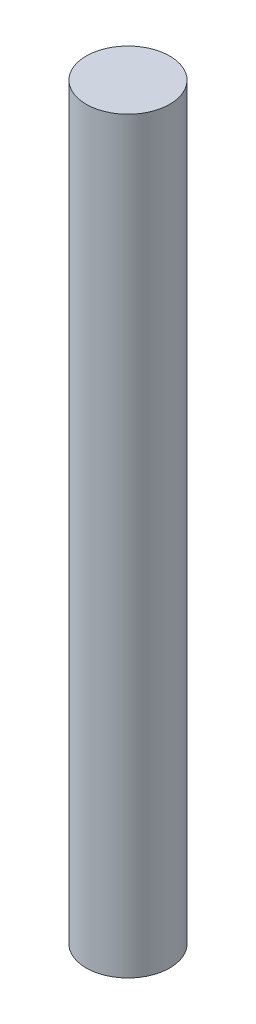
from build123d import *

# Parameters (mm, degrees)
SKETCH1_R           = 1.9
BOSS_EXTRUDE1_DEPTH = 34


with BuildPart() as part:
    # Sketch1 → Boss-Extrude1 (new body)
    with BuildSketch(Plane(origin=(0, 0, 0), x_dir=(1, 0, 0), z_dir=(0, 1, 0))):
        Circle(SKETCH1_R)
    extrude(amount=BOSS_EXTRUDE1_DEPTH)


solid = part.part
